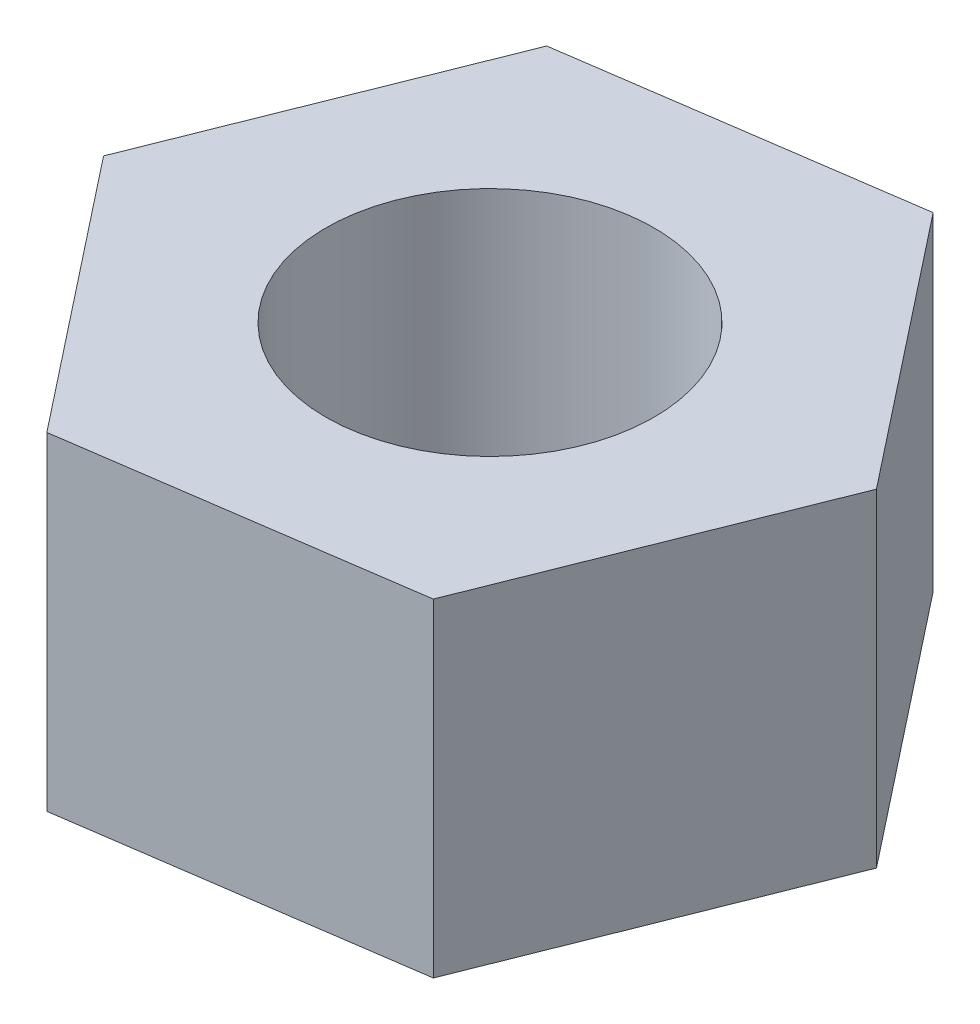
from build123d import *

# Parameters (mm, degrees)
BOSS_EXTRUDE1_DEPTH = 3
SKETCH3_R           = 1.5
CUT_EXTRUDE1_DEPTH  = 3


with BuildPart() as part:
    # Sketch2 → Boss-Extrude1 (new body)
    with BuildSketch(Plane(origin=(0, 0, 0), x_dir=(1, 0, 0), z_dir=(0, 1, 0))):
        Polygon((1.930071213, -2.448433196), (3.085440953, 0.447274104), (1.155369741, 2.895707299), (-1.930071213, 2.448433196), (-3.085440953, -0.447274104), (-1.155369741, -2.895707299), align=None)
    extrude(amount=BOSS_EXTRUDE1_DEPTH)

    # Sketch3 → Cut-Extrude1 (cut)
    with BuildSketch(Plane(origin=(0, 3, 0), x_dir=(1, 0, 0), z_dir=(0, 1, 0))):
        Circle(SKETCH3_R)
    extrude(amount=-CUT_EXTRUDE1_DEPTH, mode=Mode.SUBTRACT)


solid = part.part
